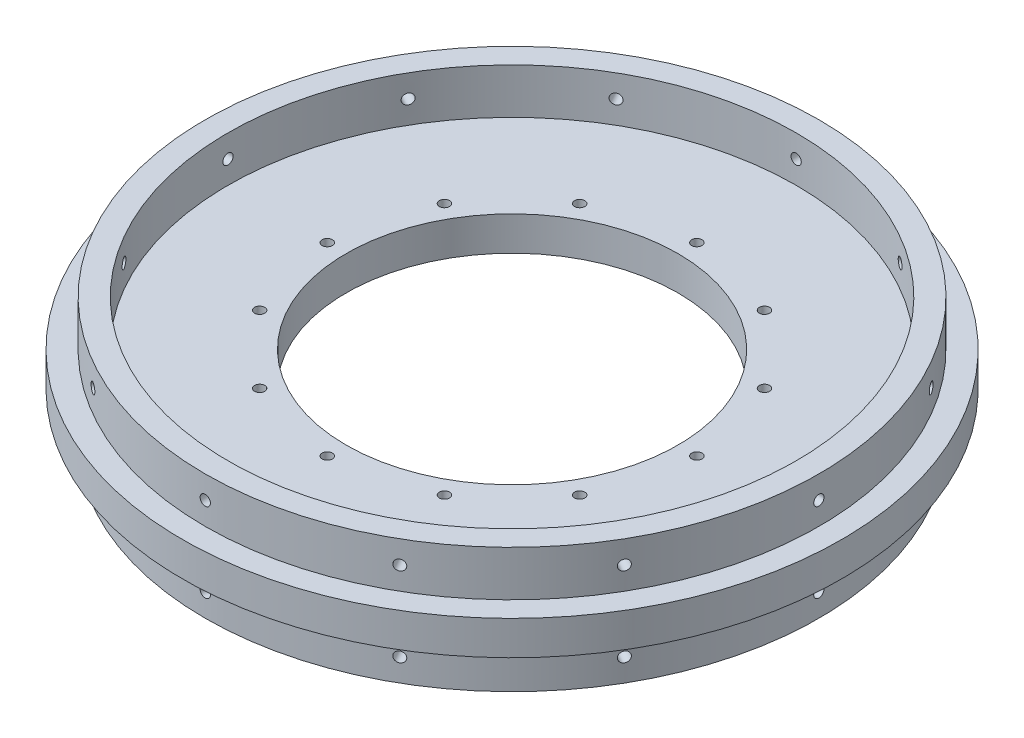
from build123d import *

# Parameters (mm, degrees)
SKETCH1_W           = 127.635
SKETCH1_H           = 127.635
BOSS_EXTRUDE1_DEPTH = 9.525
SKETCH12_R          = 92.075
BOSS_EXTRUDE2_DEPTH = 9.525
SKETCH5_R           = 46.355
CUT_EXTRUDE1_DEPTH  = 9.525
SKETCH11_R          = 1.4351
CUT_EXTRUDE3_DEPTH  = 10.525
CIRPATTERN1_COUNT   = 12
SKETCH30_R          = 85.725
SKETCH30_R_2        = 79.375
BOSS_EXTRUDE3_DEPTH = 12.7
SKETCH32_R          = 1.4351
CUT_EXTRUDE4_DEPTH  = 15.24
CIRPATTERN2_COUNT   = 12


with BuildPart() as part:
    # Sketch1 → Boss-Extrude1 (new body)
    with BuildSketch(Plane(origin=(0, 0, 0), x_dir=(1, 0, 0), z_dir=(0, 1, 0))):
        with Locations((63.8175, 63.8175)):
            Rectangle(SKETCH1_W, SKETCH1_H)
    extrude(amount=BOSS_EXTRUDE1_DEPTH)

    # Sketch12 → Boss-Extrude2 (add)
    with BuildSketch(Plane.XZ):
        with Locations((63.8175, -63.8175)):
            Circle(SKETCH12_R)
    extrude(amount=-BOSS_EXTRUDE2_DEPTH)

    # Sketch5 → Cut-Extrude1 (cut)
    with BuildSketch(Plane(origin=(0, 9.525, 0), x_dir=(1, 0, 0), z_dir=(0, 1, 0))):
        with Locations((63.8175, 63.8175)):
            Circle(SKETCH5_R)
    extrude(amount=-CUT_EXTRUDE1_DEPTH, mode=Mode.SUBTRACT)

    # Sketch11 → Cut-Extrude3 (cut, through all)
    with BuildSketch(Plane(origin=(0, 9.525, 0), x_dir=(1, 0, 0), z_dir=(0, 1, 0))):
        with Locations((63.8175, 115.443)):
            Circle(SKETCH11_R)
    cut_extrude3 = extrude(amount=-CUT_EXTRUDE3_DEPTH, mode=Mode.SUBTRACT)

    # CirPattern1: Cut-Extrude3 ×12 about axis
    cirpattern1_axis = Axis((63.8175, 0, -63.8175), (0, 1, 0))
    for i in range(1, CIRPATTERN1_COUNT):
        add(cut_extrude3.rotate(cirpattern1_axis, i * 360 / CIRPATTERN1_COUNT), mode=Mode.SUBTRACT)

    # Sketch30 → Boss-Extrude3 (add)
    with BuildSketch(Plane.XZ):
        with Locations((63.8175, -63.8175)):
            Circle(SKETCH30_R)
        with Locations((63.8175, -63.8175)):
            Circle(SKETCH30_R_2, mode=Mode.SUBTRACT)
    boss_extrude3 = extrude(amount=BOSS_EXTRUDE3_DEPTH)

    # Mirror1: Boss-Extrude3 across plane
    add(boss_extrude3.mirror(Plane.ZX.offset(4.7625)))

    # Sketch32 → Cut-Extrude4 (cut)
    with BuildSketch(Plane(origin=(0, 0, -149.5425), x_dir=(-1, 0, 0), z_dir=(0, 0, -1))):
        with Locations((-63.8175, -6.35)):
            Circle(SKETCH32_R)
        with Locations((-63.8175, 15.875)):
            Circle(SKETCH32_R)
    cut_extrude4 = extrude(amount=-CUT_EXTRUDE4_DEPTH, mode=Mode.SUBTRACT)

    # CirPattern2: Cut-Extrude4 ×12 about axis
    cirpattern2_axis = Axis((63.8175, -12.7, -63.8175), (0, 1, 0))
    for i in range(1, CIRPATTERN2_COUNT):
        add(cut_extrude4.rotate(cirpattern2_axis, i * 360 / CIRPATTERN2_COUNT), mode=Mode.SUBTRACT)


solid = part.part
